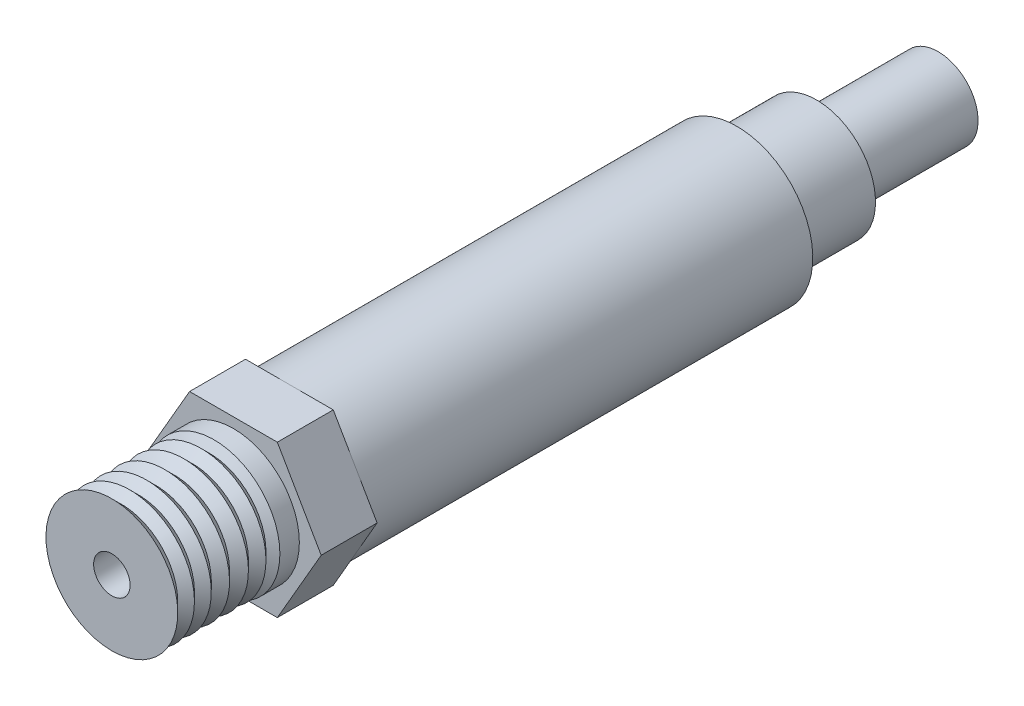
from build123d import *

# Parameters (mm, degrees)
SKETCH1_R          = 6.8834
EXTRUDE1_DEPTH     = 10.668
SKETCH1_2_R        = 6.8834
EXTRUDE2_DEPTH     = 2.032
SKETCH3_R          = 1.905
CUT_EXTRUDE1_DEPTH = 6.35
EXTRUDE3_DEPTH     = 5.842
SKETCH5_R          = 7.9375
EXTRUDE4_DEPTH     = 46.736
SKETCH6_R          = 6.1515625
EXTRUDE5_DEPTH     = 8.334375
SKETCH7_R          = 4.1671875
EXTRUDE6_DEPTH     = 12.7


with BuildPart() as part:
    # Sketch1 → Extrude1 (new body)
    with BuildSketch(Plane.XY):
        Circle(SKETCH1_R)
    extrude(amount=EXTRUDE1_DEPTH)

    # Sketch2 → Cut-Revolve5 (revolve, cut)
    with BuildSketch(Plane(origin=(0, 0, 0), x_dir=(0, 0, -1), z_dir=(1, 0, 0))):
        Polygon((-10.668, 6.8834), (-9.672936951, 5.888336951), (-8.802379845, 6.758894057), (-7.921944961, 5.878459173), (-7.041510078, 6.758894057), (-6.089928941, 5.80731292), (-5.138347804, 6.758894057), (-4.15119354, 5.771739793), (-3.164039276, 6.758894057), (-2.248031266, 5.842886047), (-1.332023256, 6.758894057), (-0.514702762, 5.941573563), (0, 6.8834), align=None)
    revolve(axis=Axis((0, 0, 12.00396124), (0, 0, -1)), mode=Mode.SUBTRACT)

    # Sketch1_2 → Extrude2 (add)
    with BuildSketch(Plane.XY):
        Circle(SKETCH1_2_R)
    extrude(amount=-EXTRUDE2_DEPTH)

    # Sketch3 → Cut-Extrude1 (cut)
    with BuildSketch(Plane.XY.offset(10.668)):
        Circle(SKETCH3_R)
    extrude(amount=-CUT_EXTRUDE1_DEPTH, mode=Mode.SUBTRACT)

    # Sketch4 → Extrude3 (add)
    with BuildSketch(Plane(origin=(0, 0, -2.032), x_dir=(-1, 0, 0), z_dir=(0, 0, -1))):
        Polygon((-4.582717762, 7.9375), (4.582717762, 7.9375), (9.165435523, 0), (4.582717762, -7.9375), (-4.582717762, -7.9375), (-9.165435523, 0), align=None)
    extrude(amount=EXTRUDE3_DEPTH)

    # Sketch5 → Extrude4 (add)
    with BuildSketch(Plane(origin=(0, 0, -7.874), x_dir=(-1, 0, 0), z_dir=(0, 0, -1))):
        Circle(SKETCH5_R)
    extrude(amount=EXTRUDE4_DEPTH)

    # Sketch6 → Extrude5 (add)
    with BuildSketch(Plane(origin=(0, 0, -54.61), x_dir=(-1, 0, 0), z_dir=(0, 0, -1))):
        Circle(SKETCH6_R)
    extrude(amount=EXTRUDE5_DEPTH)

    # Sketch7 → Extrude6 (add)
    with BuildSketch(Plane(origin=(0, 0, -62.944375), x_dir=(-1, 0, 0), z_dir=(0, 0, -1))):
        Circle(SKETCH7_R)
    extrude(amount=EXTRUDE6_DEPTH)


solid = part.part
